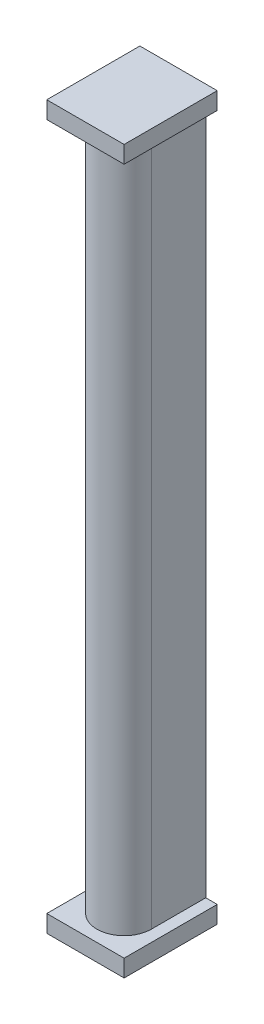
from build123d import *

# Parameters (mm, degrees)
BOSS_EXTRUDE1_DEPTH = 120
SKETCH8_W           = 13.5
SKETCH8_H           = 16.25
BOSS_EXTRUDE4_DEPTH = 3
SKETCH9_W           = 13.5
SKETCH9_H           = 16.25
BOSS_EXTRUDE5_DEPTH = 3


with BuildPart() as part:
    # Sketch5 → Boss-Extrude1 (new body)
    with BuildSketch(Plane(origin=(0, 0, 0), x_dir=(1, 0, 0), z_dir=(0, 1, 0))):
        with BuildLine():
            Line((0, 0), (9.5, 0))
            Line((9.5, 0), (9.5, -9.5))
            ThreePointArc((9.5, -9.5), (4.75, -14.25), (0, -9.5))
            Line((0, -9.5), (0, 0))
        make_face()
    extrude(amount=-BOSS_EXTRUDE1_DEPTH)

    # Sketch8 → Boss-Extrude4 (add)
    with BuildSketch(Plane.XZ.offset(120)):
        with Locations((4.75, 8.125)):
            Rectangle(SKETCH8_W, SKETCH8_H)
    extrude(amount=BOSS_EXTRUDE4_DEPTH)

    # Sketch9 → Boss-Extrude5 (add)
    with BuildSketch(Plane(origin=(0, 0, 0), x_dir=(1, 0, 0), z_dir=(0, 1, 0))):
        with Locations((4.75, -8.125)):
            Rectangle(SKETCH9_W, SKETCH9_H)
    extrude(amount=BOSS_EXTRUDE5_DEPTH)


solid = part.part
